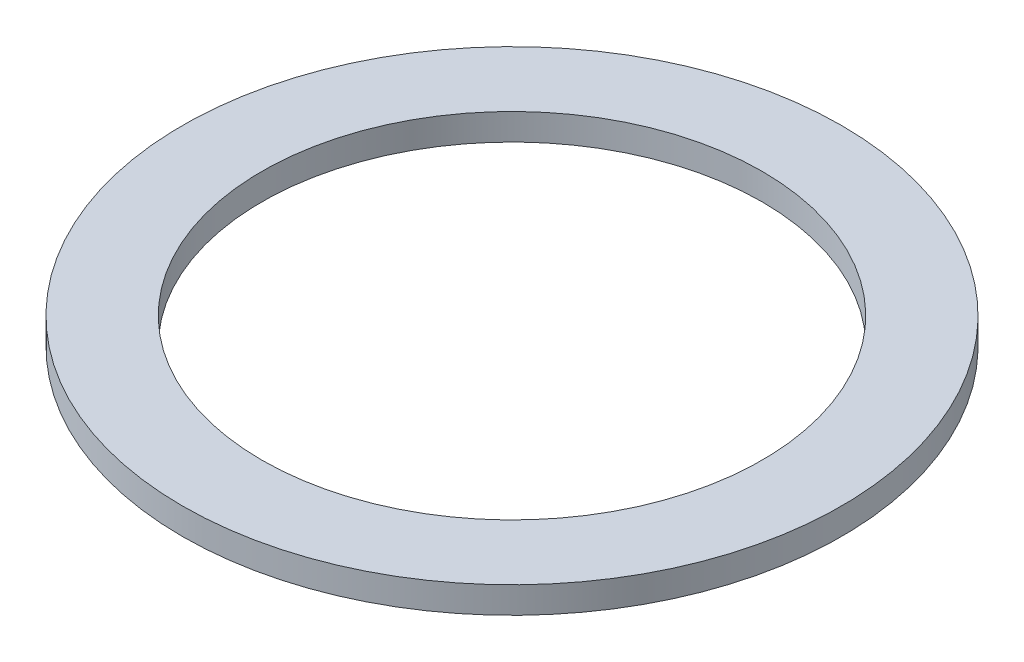
from build123d import *

# Parameters (mm, degrees)
SKETCH1_R           = 6.3246
BOSS_EXTRUDE1_DEPTH = 0.508
SKETCH5_R           = 4.8006
CUT_EXTRUDE1_DEPTH  = 1.508


with BuildPart() as part:
    # Sketch1 → Boss-Extrude1 (new body)
    with BuildSketch(Plane(origin=(0, 0, 0), x_dir=(1, 0, 0), z_dir=(0, 1, 0))):
        Circle(SKETCH1_R)
    extrude(amount=BOSS_EXTRUDE1_DEPTH)

    # Sketch5 → Cut-Extrude1 (cut, through all)
    with BuildSketch(Plane(origin=(0, 0.508, 0), x_dir=(-1, 0, 0), z_dir=(0, 1, 0))):
        Circle(SKETCH5_R)
    extrude(amount=-CUT_EXTRUDE1_DEPTH, mode=Mode.SUBTRACT)


solid = part.part
